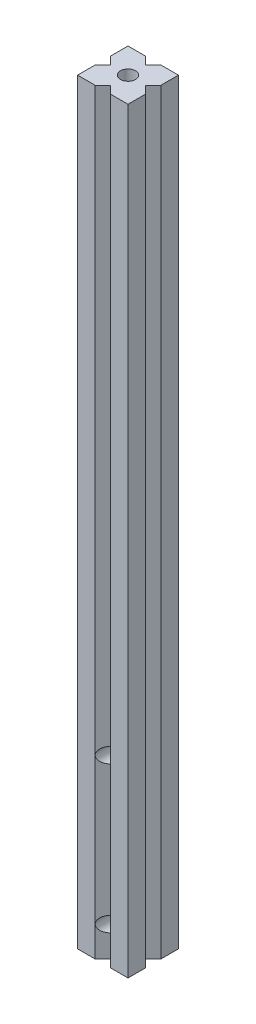
from build123d import *

# Parameters (mm, degrees)
SKIZZE1_W                       = 20
SKIZZE1_H                       = 20
AUFSATZ_LINEAR_AUSTRAGEN1_DEPTH = 300
SCHNITT_LINEAR_AUSTRAGEN1_DEPTH = 301
SKIZZE3_R                       = 3
SCHNITT_LINEAR_AUSTRAGEN2_DEPTH = 301
SKETCH1_R                       = 3
CUT_EXTRUDE1_DEPTH              = 21


with BuildPart() as part:
    # Skizze1 → Aufsatz-Linear austragen1 (new body)
    with BuildSketch(Plane(origin=(0, 0, 0), x_dir=(1, 0, 0), z_dir=(0, 1, 0))):
        with Locations((10, 10)):
            Rectangle(SKIZZE1_W, SKIZZE1_H)
    extrude(amount=AUFSATZ_LINEAR_AUSTRAGEN1_DEPTH)

    # Skizze2 → Schnitt-Linear austragen1 (cut, through all)
    with BuildSketch(Plane(origin=(0, 300, 0), x_dir=(1, 0, 0), z_dir=(0, 1, 0))):
        Polygon((7, 20), (10, 17), (13, 20), align=None)
        Polygon((20, 13), (17, 10), (20, 7), align=None)
        Polygon((0, 7), (0, 13), (3, 10), align=None)
        Polygon((7, 0), (13, 0), (10, 3), align=None)
    extrude(amount=-SCHNITT_LINEAR_AUSTRAGEN1_DEPTH, mode=Mode.SUBTRACT)

    # Skizze3 → Schnitt-Linear austragen2 (cut, through all)
    with BuildSketch(Plane(origin=(0, 300, 0), x_dir=(1, 0, 0), z_dir=(0, 1, 0))):
        with Locations((10, 10)):
            Circle(SKIZZE3_R)
    extrude(amount=-SCHNITT_LINEAR_AUSTRAGEN2_DEPTH, mode=Mode.SUBTRACT)

    # Sketch1 → Cut-Extrude1 (cut, through all)
    with BuildSketch(Plane.XY):
        with Locations((10, 12)):
            Circle(SKETCH1_R)
        with Locations((10, 70)):
            Circle(SKETCH1_R)
    extrude(amount=-CUT_EXTRUDE1_DEPTH, mode=Mode.SUBTRACT)


solid = part.part
